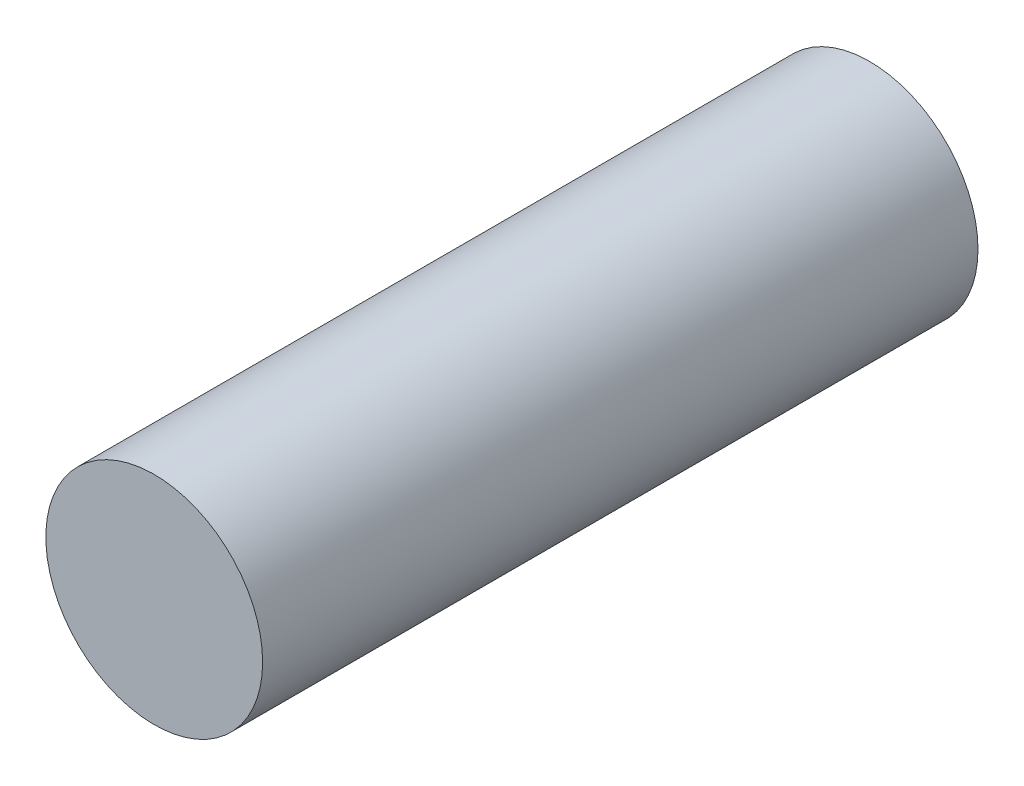
from build123d import *

# Parameters (mm, degrees)
SKETCH1_R           = 6.35
BOSS_EXTRUDE1_DEPTH = 41.91


with BuildPart() as part:
    # Sketch1 → Boss-Extrude1 (new body)
    with BuildSketch(Plane.XY):
        Circle(SKETCH1_R)
    extrude(amount=BOSS_EXTRUDE1_DEPTH)


solid = part.part
